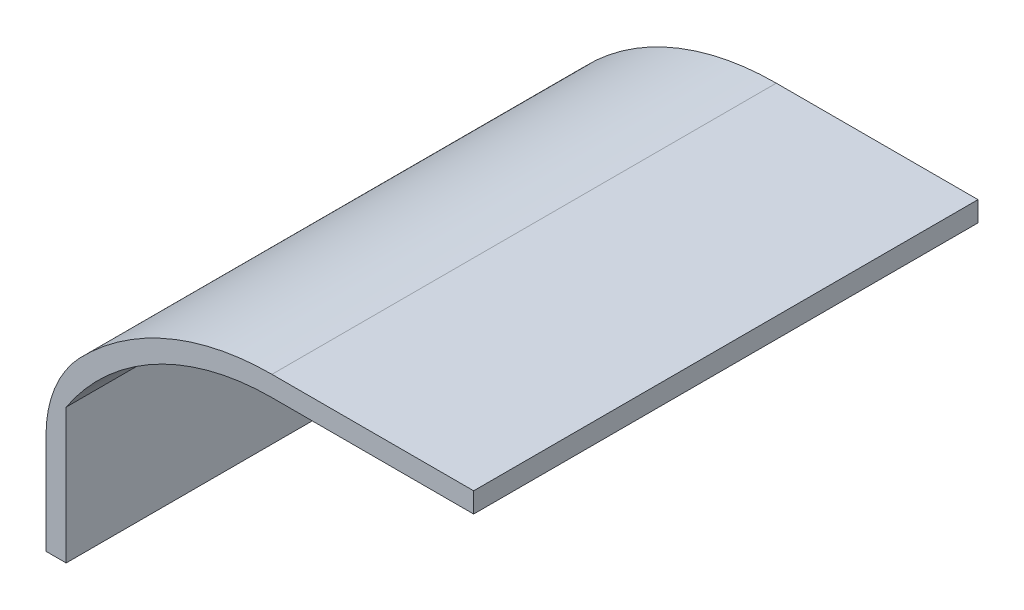
from build123d import *

# Parameters (mm, degrees)
EXTRUDE_1_DEPTH = 125
FILLET_1_R      = 30


with BuildPart() as part:
    # ｽｹｯﾁ1 → ﾎﾞｽ - 押し出し1 (new body)
    with BuildSketch(Plane.XY):
        with BuildLine():
            Line((-101, 0), (-101, 33.466401061))
            ThreePointArc((-101, 33.466401061), (-78.978867604, 53.677045675), (-50, 61))
            Line((-50, 61), (0, 61))
            Line((0, 61), (0, 66))
            Line((0, 66), (-50, 66))
            ThreePointArc((-50, 66), (-82.02123597, 57.711701127), (-106, 34.928498393))
            Line((-106, 34.928498393), (-106, 0))
            Line((-106, 0), (-101, 0))
        make_face()
    extrude(amount=EXTRUDE_1_DEPTH)

    # ﾌｨﾚｯﾄ1
    fillet_1_edges = [part.edges().sort_by_distance(p)[0] for p in [
        (-106, 34.928498393, 62.5),
    ]]
    fillet(fillet_1_edges, radius=FILLET_1_R)


solid = part.part
